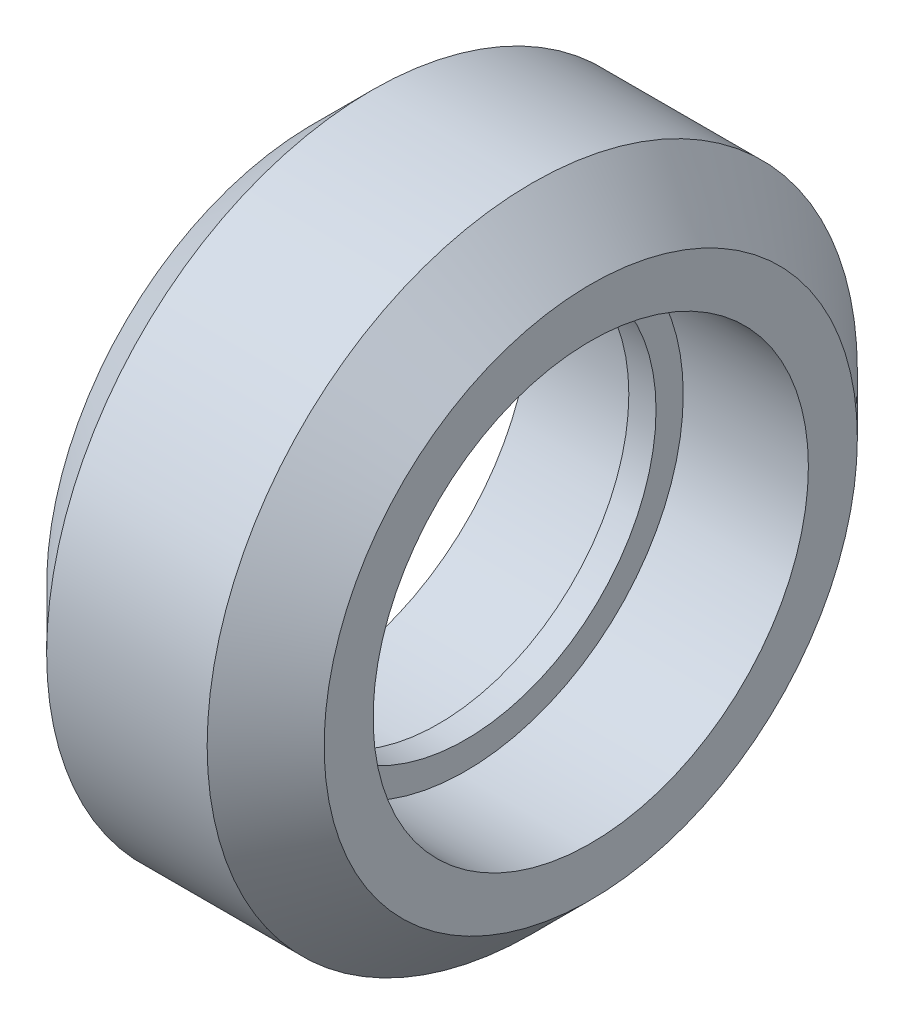
from build123d import *


with BuildPart() as part:
    # Sketch1 → Revolve1 (revolve)
    with BuildSketch(Plane.XY):
        Polygon((0.5, 7), (-0.5, 7), (-0.5, 8), (-5.1, 8), (-5.1, 9.8), (-2.95, 11.95), (2.95, 11.95), (5.1, 9.8), (5.1, 8), (0.5, 8), align=None)
    revolve(axis=Axis((0, 0, 0), (-1, 0, 0)))


solid = part.part
